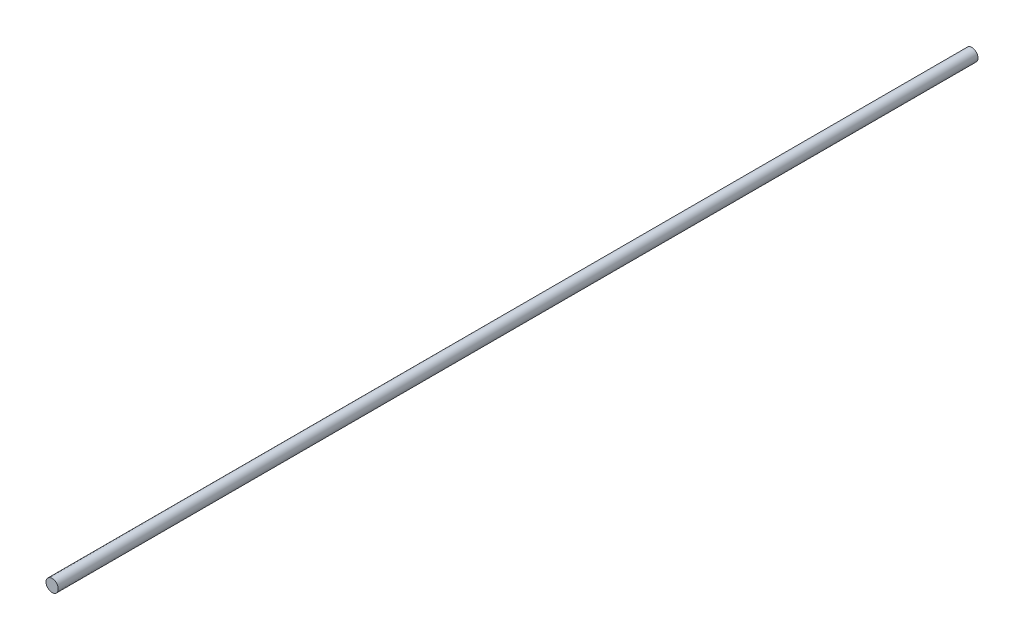
from build123d import *

# Parameters (mm, degrees)
ESQUISSE1_R        = 4
BOSS_EXTRU_1_DEPTH = 600


with BuildPart() as part:
    # Esquisse1 → Boss.-Extru.1 (new body)
    with BuildSketch(Plane.XY):
        Circle(ESQUISSE1_R)
    extrude(amount=BOSS_EXTRU_1_DEPTH)


solid = part.part
